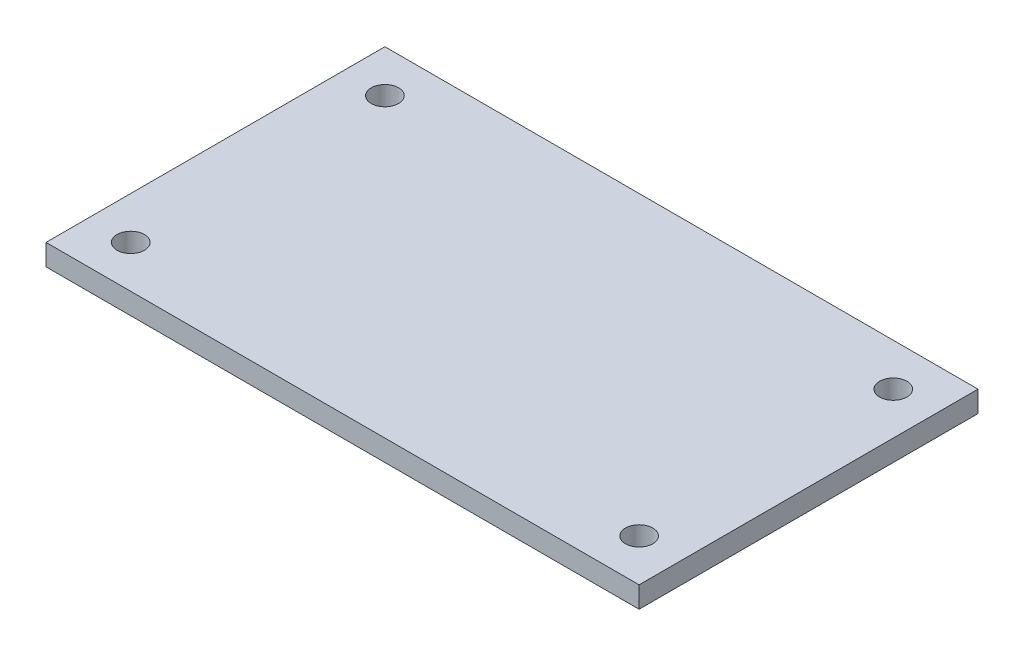
from build123d import *

# Parameters (mm, degrees)
SKETCH1_W                = 177.8
SKETCH1_H                = 101.6
BOSS_EXTRUDE1_DEPTH      = 6.35
P_0_323_DIAMETER_HOLE1_D = 8.2042


with BuildPart() as part:
    # Sketch1 → Boss-Extrude1 (new body)
    with BuildSketch(Plane(origin=(0, 0, 0), x_dir=(1, 0, 0), z_dir=(0, 1, 0))):
        Rectangle(SKETCH1_W, SKETCH1_H)
    extrude(amount=-BOSS_EXTRUDE1_DEPTH)

    # P (0.323) Diameter Hole1 (through all)
    with Locations(Plane(origin=(0, 0, 0), x_dir=(1, 0, 0), z_dir=(0, 1, 0))):
        with Locations((-76.2, 38.1), (-76.2, -38.1), (76.2, -38.1), (76.2, 38.1)):
            Hole(P_0_323_DIAMETER_HOLE1_D / 2)


solid = part.part
